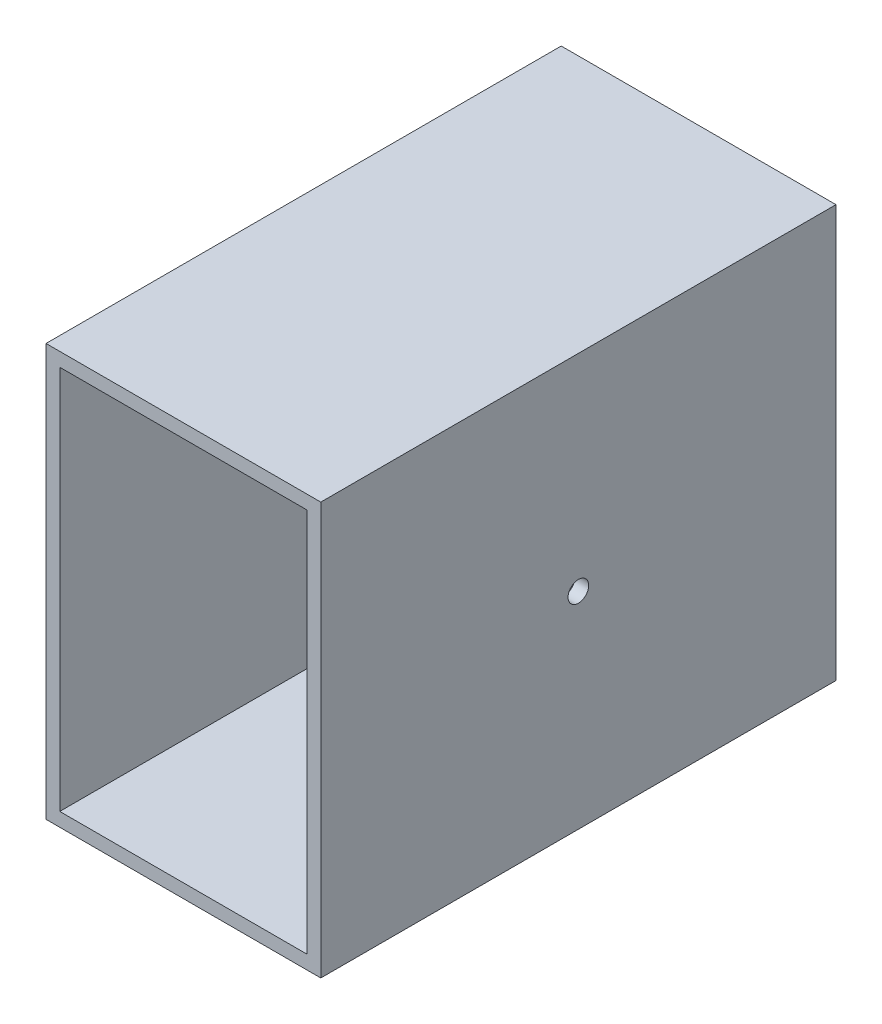
from build123d import *

# Parameters (mm, degrees)
SKETCH1_W           = 80
SKETCH1_H           = 120
SKETCH1_W_2         = 72
SKETCH1_H_2         = 112
BOSS_EXTRUDE1_DEPTH = 150
SKETCH2_R           = 3
CUT_EXTRUDE1_DEPTH  = 73


with BuildPart() as part:
    # Sketch1 → Boss-Extrude1 (new body)
    with BuildSketch(Plane.XY):
        with Locations((-36, 56)):
            Rectangle(SKETCH1_W, SKETCH1_H)
        with Locations((-36, 56)):
            Rectangle(SKETCH1_W_2, SKETCH1_H_2, mode=Mode.SUBTRACT)
    extrude(amount=BOSS_EXTRUDE1_DEPTH)

    # Sketch2 → Cut-Extrude1 (cut)
    with BuildSketch(Plane(origin=(4, 0, 0), x_dir=(0, 0, -1), z_dir=(1, 0, 0))):
        with Locations((-75, 56)):
            Circle(SKETCH2_R)
    extrude(amount=-CUT_EXTRUDE1_DEPTH, mode=Mode.SUBTRACT)


solid = part.part
